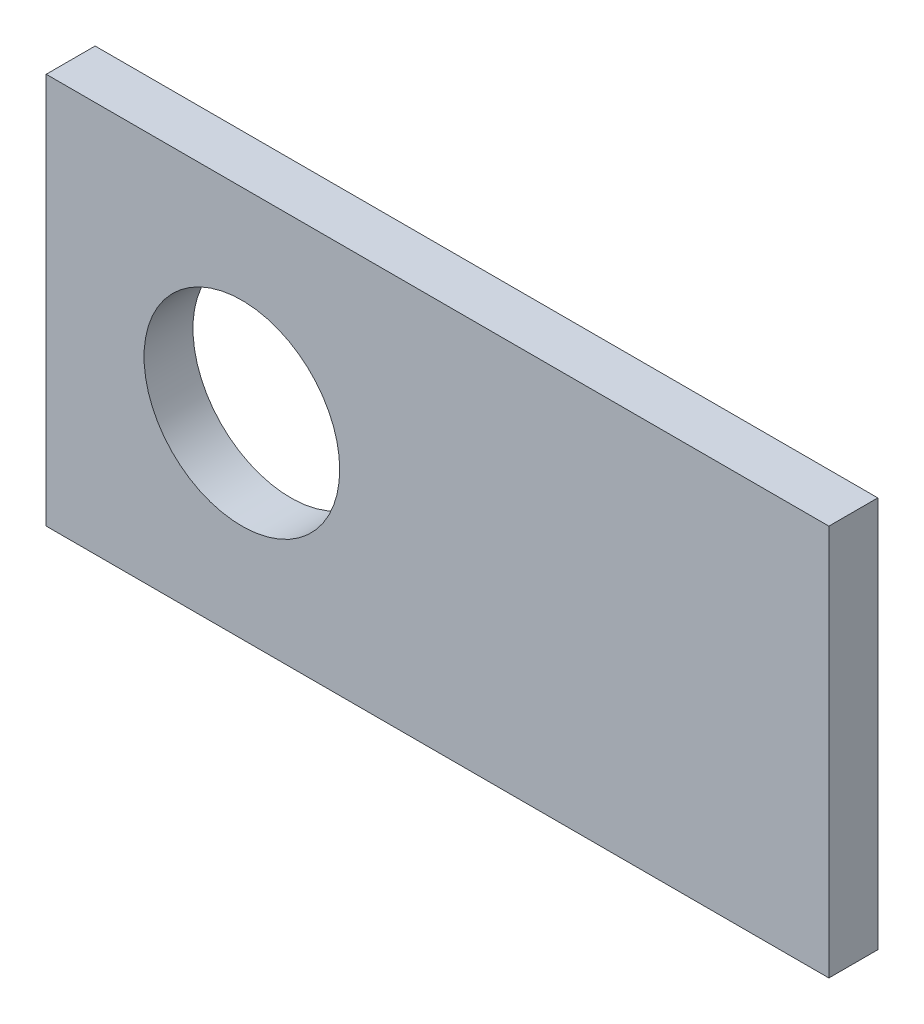
from build123d import *

# Parameters (mm, degrees)
SKETCH1_W           = 50.8
SKETCH1_H           = 25.4
SKETCH1_R           = 6.35
BOSS_EXTRUDE1_DEPTH = 3.175


with BuildPart() as part:
    # Sketch1 → Boss-Extrude1 (new body)
    with BuildSketch(Plane.XY):
        with Locations((25.4, 12.7)):
            Rectangle(SKETCH1_W, SKETCH1_H)
        with Locations((12.7, 12.7)):
            Circle(SKETCH1_R, mode=Mode.SUBTRACT)
    extrude(amount=BOSS_EXTRUDE1_DEPTH)


solid = part.part
